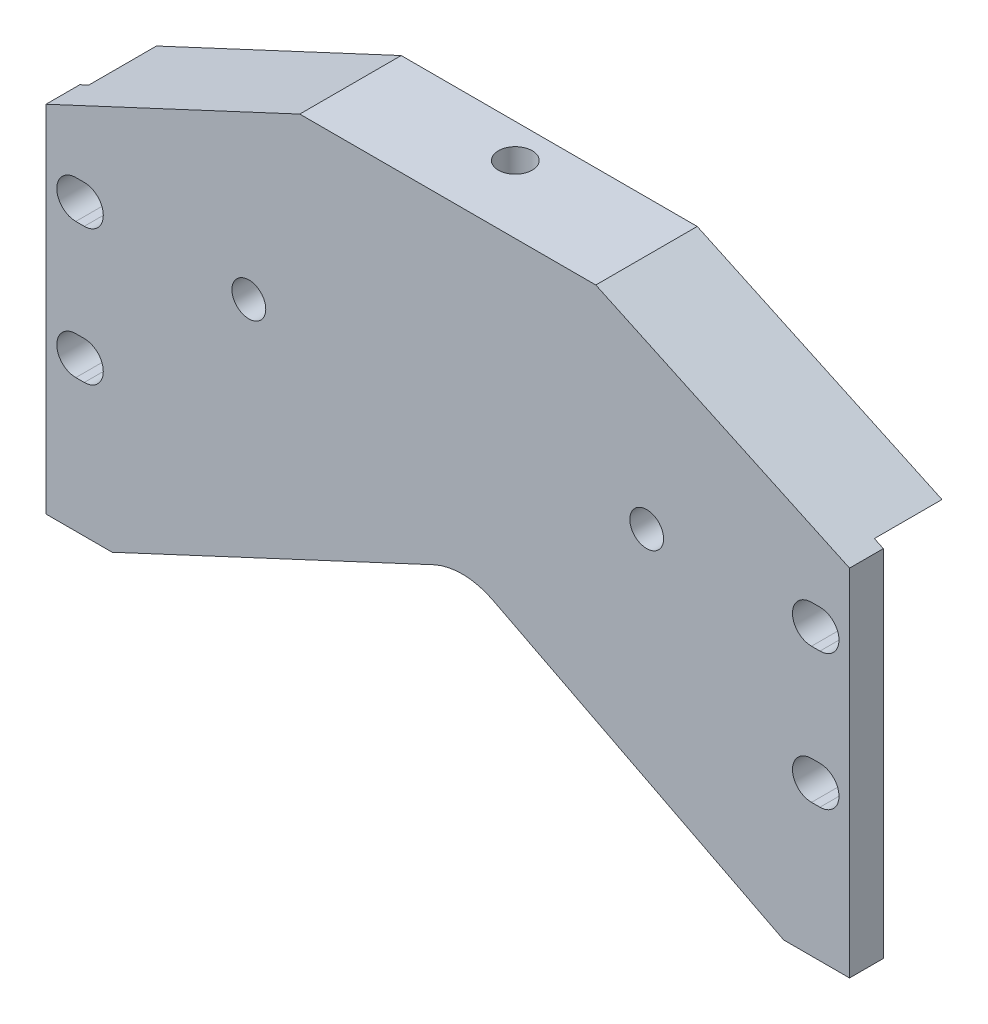
from build123d import *

# Parameters (mm, degrees)
BASE_EXTRUDE_DEPTH             = 12.7
F_9_16_0_5625_DIAMETER_HOLE1_D = 14.2875
CUT_EXTRUDE1_DEPTH             = 13.7
BOSS_EXTRUDE1_DEPTH            = 25.4
F_1_2_20_TAPPED_HOLE1_D        = 12.7
CUT_EXTRUDE2_DEPTH             = 39.1
CUT_EXTRUDE3_DEPTH             = 39.1
F_1_2_20_TAPPED_HOLE2_D        = 12.7
CUT_EXTRUDE4_DEPTH             = 25.4


with BuildPart() as part:
    # Sketch1 → Base-Extrude (new body)
    with BuildSketch(Plane.XY):
        Polygon((58.12164787, 111.098459585), (-37.201684746, 66.648459585), (-37.201684746, -66.701540415), (264.657388756, -66.701540415), (264.657388756, 66.648459585), (169.334056139, 111.098459585), align=None)
    extrude(amount=BASE_EXTRUDE_DEPTH)

    # 9/16 (0.5625) Diameter Hole1 (through all)
    with Locations(Plane.XY.offset(12.7)):
        with Locations((251.957388756, -9.551540415), (251.957388756, 41.248459585)):
            f_9_16_0_5625_diameter_hole1 = Hole(F_9_16_0_5625_DIAMETER_HOLE1_D / 2)

    # Sketch8 → Cut-Extrude1 (cut, through all)
    with BuildSketch(Plane.XY.offset(12.7)):
        with BuildLine():
            Line((-12.371439248, -66.701540415), (239.908029755, -66.701540415))
            Line((239.908029755, -66.701540415), (130.710820593, -10.795488361))
            ThreePointArc((130.710820593, -10.795488361), (119.603489866, -8.008935492), (108.401043329, -10.384406895))
            Line((108.401043329, -10.384406895), (-12.371439248, -66.701540415))
        make_face()
    extrude(amount=-CUT_EXTRUDE1_DEPTH, mode=Mode.SUBTRACT)

    # Mirror3: 9/16 (0.5625) Diameter Hole1 across plane
    add(f_9_16_0_5625_diameter_hole1.mirror(Plane(origin=(113.768295254, 0, 0), x_dir=(0, 0, 1), z_dir=(1, 0, 0))), mode=Mode.SUBTRACT)

    # Sketch10 → Boss-Extrude1 (add)
    with BuildSketch(Plane(origin=(0, 0, 0), x_dir=(-1, 0, 0), z_dir=(0, 0, -1))):
        Polygon((-169.334056139, 111.098459585), (-58.12164787, 111.098459585), (33.824515248, 68.223259585), (-261.280219258, 68.223259585), align=None)
    extrude(amount=BOSS_EXTRUDE1_DEPTH)

    # 1/2-20 Tapped Hole1 (through all)
    with Locations(Plane(origin=(0, 111.098459585, 0), x_dir=(-1, 0, 0), z_dir=(0, 1, 0))):
        with Locations((-113.69684787, -12.7)):
            Hole(F_1_2_20_TAPPED_HOLE1_D / 2)

    # Sketch13 → Cut-Extrude2 (cut, through all)
    with BuildSketch(Plane.XY.offset(12.7)):
        with BuildLine():
            Line((250.369888756, -2.407790415), (253.544888756, -2.407790415))
            ThreePointArc((253.544888756, -2.407790415), (260.688638756, -9.551540415), (253.544888756, -16.695290415))
            Line((253.544888756, -16.695290415), (250.369888756, -16.695290415))
            ThreePointArc((250.369888756, -16.695290415), (243.226138756, -9.551540415), (250.369888756, -2.407790415))
        make_face()
    cut_extrude2 = extrude(amount=-CUT_EXTRUDE2_DEPTH, mode=Mode.SUBTRACT)

    # Sketch14 → Cut-Extrude3 (cut, through all)
    with BuildSketch(Plane.XY.offset(12.7)):
        with BuildLine():
            Line((253.544888756, 48.392209585), (250.369888756, 48.392209585))
            ThreePointArc((250.369888756, 48.392209585), (243.226138756, 41.248459585), (250.369888756, 34.104709585))
            Line((250.369888756, 34.104709585), (253.544888756, 34.104709585))
            ThreePointArc((253.544888756, 34.104709585), (260.688638756, 41.248459585), (253.544888756, 48.392209585))
        make_face()
    cut_extrude3 = extrude(amount=-CUT_EXTRUDE3_DEPTH, mode=Mode.SUBTRACT)

    # Mirror4: Cut-Extrude2, Cut-Extrude3 across plane
    add(cut_extrude2.mirror(Plane(origin=(113.768295254, 0, 0), x_dir=(0, 0, 1), z_dir=(1, 0, 0))), mode=Mode.SUBTRACT)
    add(cut_extrude3.mirror(Plane(origin=(113.768295254, 0, 0), x_dir=(0, 0, 1), z_dir=(1, 0, 0))), mode=Mode.SUBTRACT)

    # 1/2-20 Tapped Hole2 (through all)
    with Locations(Plane.XY.offset(12.7)):
        with Locations((38.998315254, 41.248459585), (188.457388756, 41.248459585)):
            Hole(F_1_2_20_TAPPED_HOLE2_D / 2)

    # Sketch17 → Cut-Extrude4 (cut)
    with BuildSketch(Plane(origin=(0, 0, -25.4), x_dir=(-1, 0, 0), z_dir=(0, 0, -1))):
        with BuildLine():
            Line((-129.602852005, 68.223259585), (-97.852852005, 68.223259585))
            Line((-97.852852005, 68.223259585), (-97.852852005, 88.848059585))
            ThreePointArc((-97.852852005, 88.848059585), (-99.251475703, 92.224635886), (-102.628052005, 93.623259585))
            Line((-102.628052005, 93.623259585), (-124.827652005, 93.623259585))
            ThreePointArc((-124.827652005, 93.623259585), (-128.204228306, 92.224635886), (-129.602852005, 88.848059585))
            Line((-129.602852005, 88.848059585), (-129.602852005, 68.223259585))
        make_face()
    extrude(amount=-CUT_EXTRUDE4_DEPTH, mode=Mode.SUBTRACT)


solid = part.part
